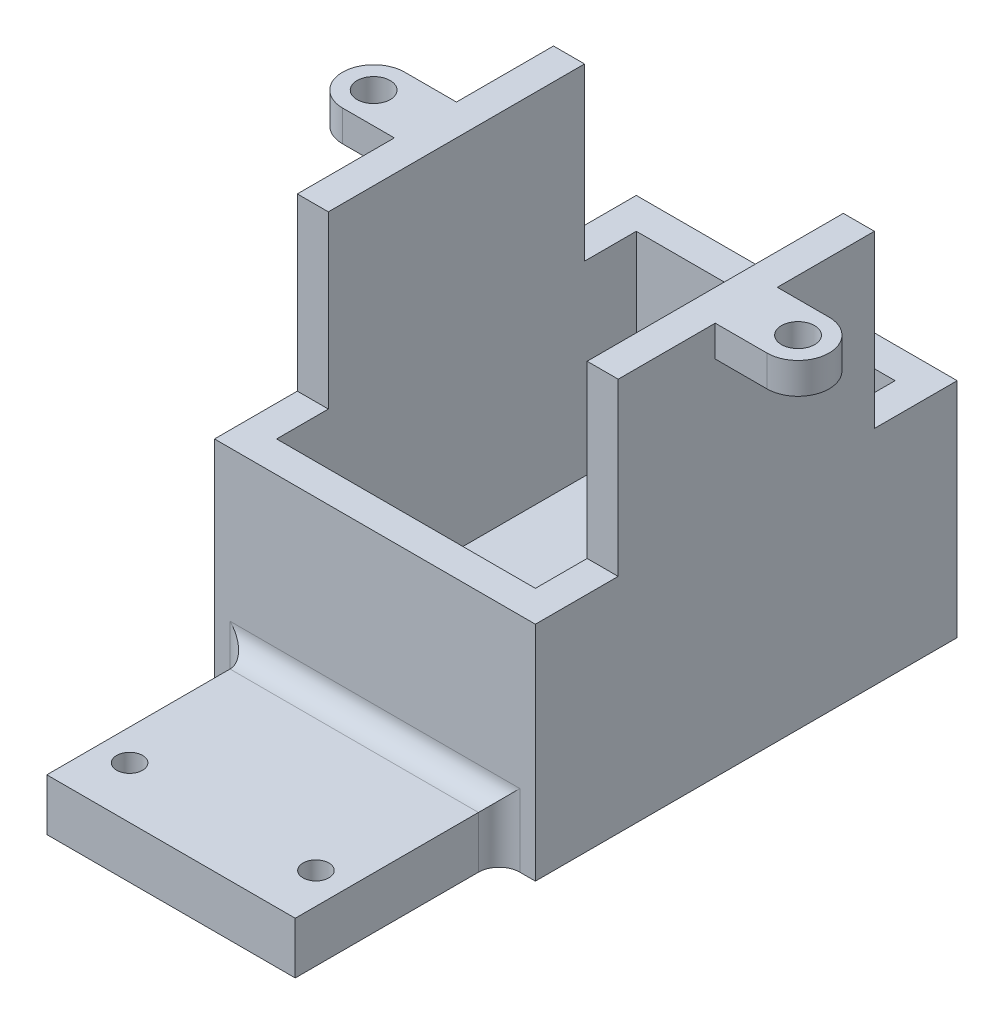
from build123d import *

# Parameters (mm, degrees)
SKETCH_1_W          = 31
SKETCH_1_H          = 38
EXTRUDE_1_DEPTH     = 40.75
SKETCH_2_W          = 8
SKETCH_2_H          = 16.5
CUT_EXTRUDE_1_DEPTH = 40.75
SKETCH_3_W          = 25
SKETCH_3_H          = 34.75
CUT_EXTRUDE_2_DEPTH = 34.5
SKETCH_4_R          = 12.5
CUT_EXTRUDE_3_DEPTH = 34.5
SKETCH_5_R          = 1.6
EXTRUDE_2_DEPTH     = 3
SKETCH_6_W          = 24
SKETCH_6_H          = 5
EXTRUDE_3_DEPTH     = 19.7
FILLET_1_R          = 2
SKETCH_7_R          = 1.25
CUT_EXTRUDE_4_DEPTH = 19.7
SKETCH_8_W          = 31
SKETCH_8_H          = 16.5
CUT_EXTRUDE_5_DEPTH = 8


with BuildPart() as part:
    # 草图1 → 凸台-拉伸1 (new body)
    with BuildSketch(Plane.XY):
        with Locations((15.5, 19)):
            Rectangle(SKETCH_1_W, SKETCH_1_H)
    extrude(amount=-EXTRUDE_1_DEPTH)

    # 草图2 → 切除-拉伸1 (cut)
    with BuildSketch(Plane(origin=(31, 0, 0), x_dir=(0, 0, -1), z_dir=(1, 0, 0))):
        with Locations((36.75, 29.75)):
            Rectangle(SKETCH_2_W, SKETCH_2_H)
    extrude(amount=-CUT_EXTRUDE_1_DEPTH, mode=Mode.SUBTRACT)

    # 草图3 → 切除-拉伸2 (cut)
    with BuildSketch(Plane(origin=(0, 38, 0), x_dir=(1, 0, 0), z_dir=(0, 1, 0))):
        with Locations((15.5, 20.375)):
            Rectangle(SKETCH_3_W, SKETCH_3_H)
    extrude(amount=-CUT_EXTRUDE_2_DEPTH, mode=Mode.SUBTRACT)

    # 草图4 → 切除-拉伸3 (cut)
    with BuildSketch(Plane.XY):
        with Locations((15.5, 38)):
            Circle(SKETCH_4_R)
    extrude(amount=-CUT_EXTRUDE_3_DEPTH, mode=Mode.SUBTRACT)

    # 草图5 → 凸台-拉伸2 (add)
    with BuildSketch(Plane(origin=(0, 38, 0), x_dir=(1, 0, 0), z_dir=(0, 1, 0))):
        with BuildLine():
            Line((36, 23.375), (31, 23.375))
            Line((31, 23.375), (31, 17.375))
            Line((31, 17.375), (36, 17.375))
            ThreePointArc((36, 17.375), (39, 20.375), (36, 23.375))
        make_face()
        with Locations((36, 20.375)):
            Circle(SKETCH_5_R, mode=Mode.SUBTRACT)
        with BuildLine():
            Line((0, 23.375), (0, 17.375))
            Line((0, 17.375), (-5, 17.375))
            ThreePointArc((-5, 17.375), (-8, 20.375), (-5, 23.375))
            Line((-5, 23.375), (0, 23.375))
        make_face()
        with Locations((-5, 20.375)):
            Circle(SKETCH_5_R, mode=Mode.SUBTRACT)
    extrude(amount=-EXTRUDE_2_DEPTH)

    # 草图6 → 凸台-拉伸3 (add)
    with BuildSketch(Plane.XY):
        with Locations((15.5, 2.5)):
            Rectangle(SKETCH_6_W, SKETCH_6_H)
    extrude(amount=EXTRUDE_3_DEPTH)

    # 圆角1
    fillet_1_edges = [part.edges().sort_by_distance(p)[0] for p in [
        (3.5, 2.5, 0),
        (27.5, 2.5, 0),
        (15.5, 5, 0),
    ]]
    fillet(fillet_1_edges, radius=FILLET_1_R)

    # 草图7 → 切除-拉伸4 (cut)
    with BuildSketch(Plane(origin=(0, 5, 0), x_dir=(1, 0, 0), z_dir=(0, 1, 0))):
        with Locations((6.5, -14.7)):
            Circle(SKETCH_7_R)
        with Locations((24.5, -14.7)):
            Circle(SKETCH_7_R)
    extrude(amount=-CUT_EXTRUDE_4_DEPTH, mode=Mode.SUBTRACT)

    # 草图8 → 切除-拉伸5 (cut)
    with BuildSketch(Plane.XY):
        with Locations((15.5, 29.75)):
            Rectangle(SKETCH_8_W, SKETCH_8_H)
    extrude(amount=-CUT_EXTRUDE_5_DEPTH, mode=Mode.SUBTRACT)


solid = part.part
